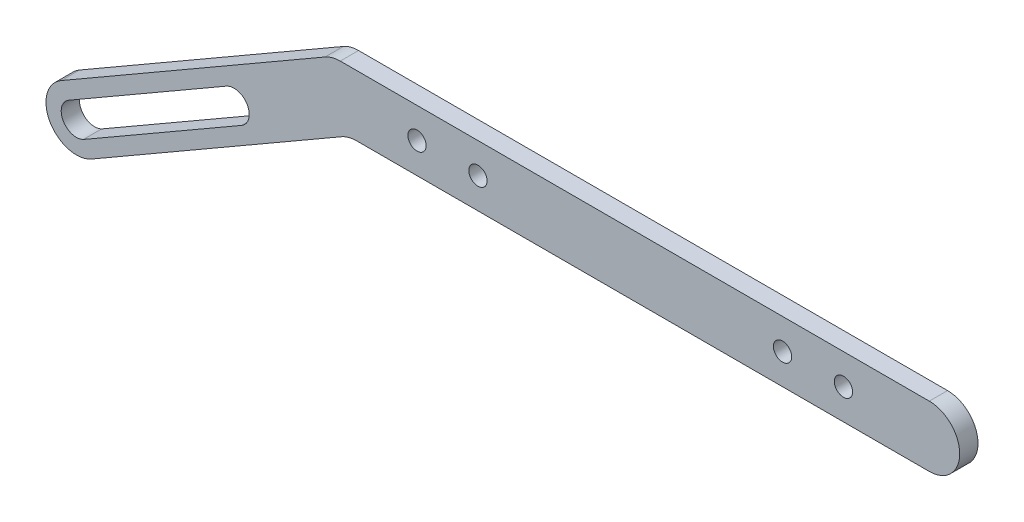
from build123d import *

# Parameters (mm, degrees)
EXTRUDE_1_DEPTH     = 3
CUT_EXTRUDE_1_DEPTH = 3
SKETCH_3_R          = 1.5
CUT_EXTRUDE_2_DEPTH = 3
SKETCH_4_R          = 1.5
CUT_EXTRUDE_3_DEPTH = 4


with BuildPart() as part:
    # 草图1 → 凸台-拉伸1 (new body)
    with BuildSketch(Plane.XY):
        with BuildLine():
            Line((-53.903075976, 5), (42.782990351, 5))
            ThreePointArc((42.782990351, 5), (47.782990351, 0), (42.782990351, -5))
            Line((42.782990351, -5), (-51.223584051, -5))
            ThreePointArc((-51.223584051, -5), (-52.517679277, -5.170370869), (-53.723584051, -5.669872981))
            Line((-53.723584051, -5.669872981), (-94.717009649, -29.337438285))
            ThreePointArc((-94.717009649, -29.337438285), (-101.547136668, -27.507311266), (-99.717009649, -20.677184247))
            Line((-99.717009649, -20.677184247), (-56.403075976, 4.330127019))
            ThreePointArc((-56.403075976, 4.330127019), (-55.197171201, 4.829629131), (-53.903075976, 5))
        make_face()
    extrude(amount=EXTRUDE_1_DEPTH)

    # 草图2 → 切除-拉伸1 (cut)
    with BuildSketch(Plane.XY.offset(3)):
        with BuildLine():
            Line((-98.334747096, -22.771095042), (-72.598059837, -7.912011725))
            ThreePointArc((-72.598059837, -7.912011725), (-69.182829293, -8.82736459), (-70.098638571, -12.242472773))
            Line((-70.098638571, -12.242472773), (-96.083409035, -27.235527963))
            ThreePointArc((-96.083409035, -27.235527963), (-99.449240201, -26.132987403), (-98.334747096, -22.771095042))
        make_face()
    extrude(amount=-CUT_EXTRUDE_1_DEPTH, mode=Mode.SUBTRACT)

    # 草图3 → 切除-拉伸2 (cut)
    with BuildSketch(Plane.XY.offset(3)):
        with Locations((-31.303593391, 0)):
            Circle(SKETCH_3_R)
        with Locations((-41.303593391, 0)):
            Circle(SKETCH_3_R)
    extrude(amount=-CUT_EXTRUDE_2_DEPTH, mode=Mode.SUBTRACT)

    # 草图4 → 切除-拉伸3 (cut, through all)
    with BuildSketch(Plane(origin=(0, 0, 0), x_dir=(-1, 0, 0), z_dir=(0, 0, -1))):
        with Locations((-18.696406609, 0)):
            Circle(SKETCH_4_R)
        with Locations((-28.696406609, 0)):
            Circle(SKETCH_4_R)
    extrude(amount=-CUT_EXTRUDE_3_DEPTH, mode=Mode.SUBTRACT)


solid = part.part
